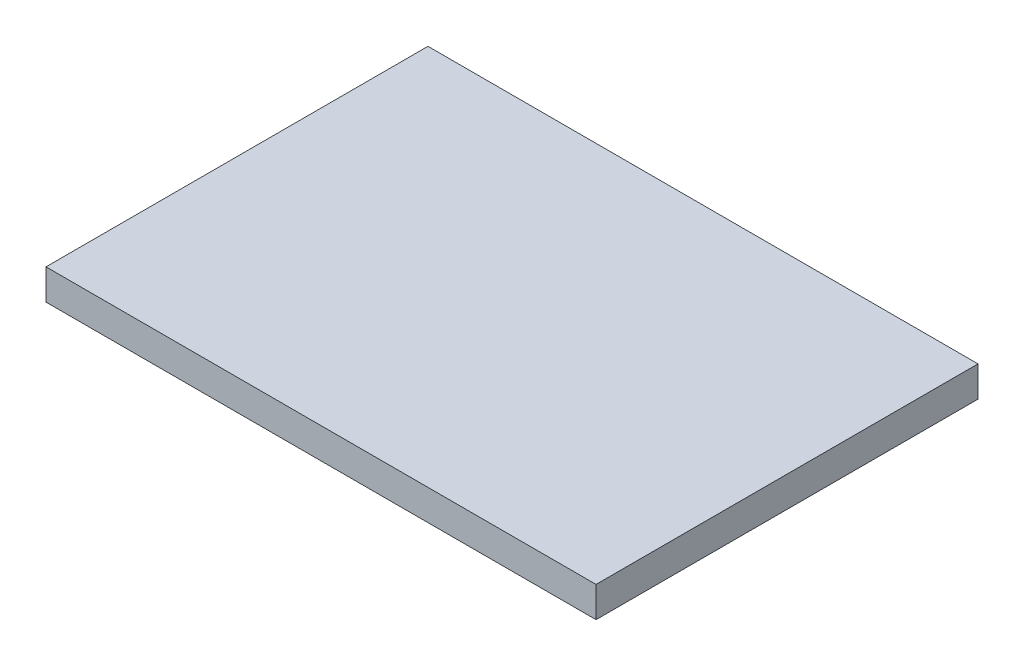
from build123d import *

# Parameters (mm, degrees)
SKETCH_1_W      = 36
SKETCH_1_H      = 25
EXTRUDE_1_DEPTH = 2


with BuildPart() as part:
    # 草图1 → 凸台-拉伸1 (new body)
    with BuildSketch(Plane(origin=(0, 0, 0), x_dir=(1, 0, 0), z_dir=(0, 1, 0))):
        Rectangle(SKETCH_1_W, SKETCH_1_H)
    extrude(amount=EXTRUDE_1_DEPTH)


solid = part.part
